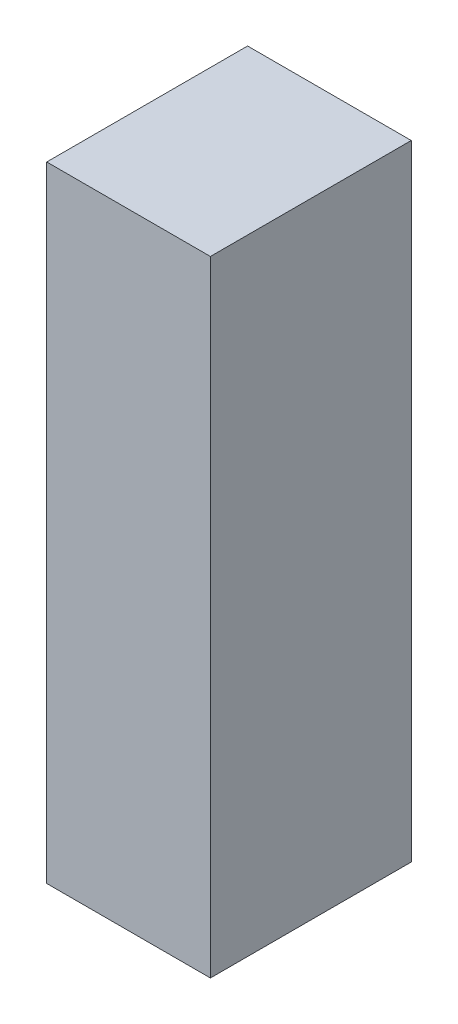
from build123d import *

# Parameters (mm, degrees)
SKETCH1_W           = 558.8
SKETCH1_H           = 685.8
BOSS_EXTRUDE1_DEPTH = 2133.6
SHELL2_T            = -2.54


with BuildPart() as part:
    # Sketch1 → Boss-Extrude1 (new body)
    with BuildSketch(Plane(origin=(0, 0, 0), x_dir=(1, 0, 0), z_dir=(0, 1, 0))):
        Rectangle(SKETCH1_W, SKETCH1_H)
    extrude(amount=BOSS_EXTRUDE1_DEPTH)

    # Shell2
    shell2_openings = [part.faces().sort_by_distance(p)[0] for p in [
        (-279.4, 1066.8, 0),
    ]]
    offset(amount=SHELL2_T, openings=shell2_openings, kind=Kind.INTERSECTION)


solid = part.part
